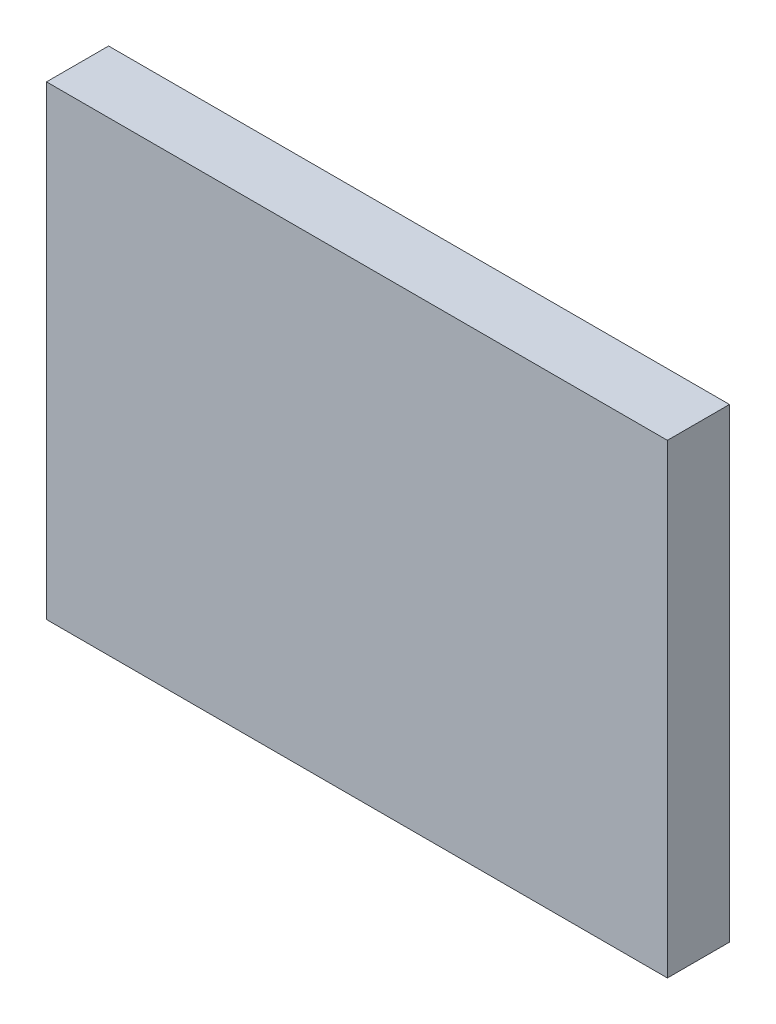
from build123d import *

# Parameters (mm, degrees)
SKETCH1_W           = 25.4
SKETCH1_H           = 19.05
BOSS_EXTRUDE1_DEPTH = 2.54


with BuildPart() as part:
    # Sketch1 → Boss-Extrude1 (new body)
    with BuildSketch(Plane.XY):
        with Locations((12.7, 9.525)):
            Rectangle(SKETCH1_W, SKETCH1_H)
    extrude(amount=BOSS_EXTRUDE1_DEPTH)


solid = part.part
